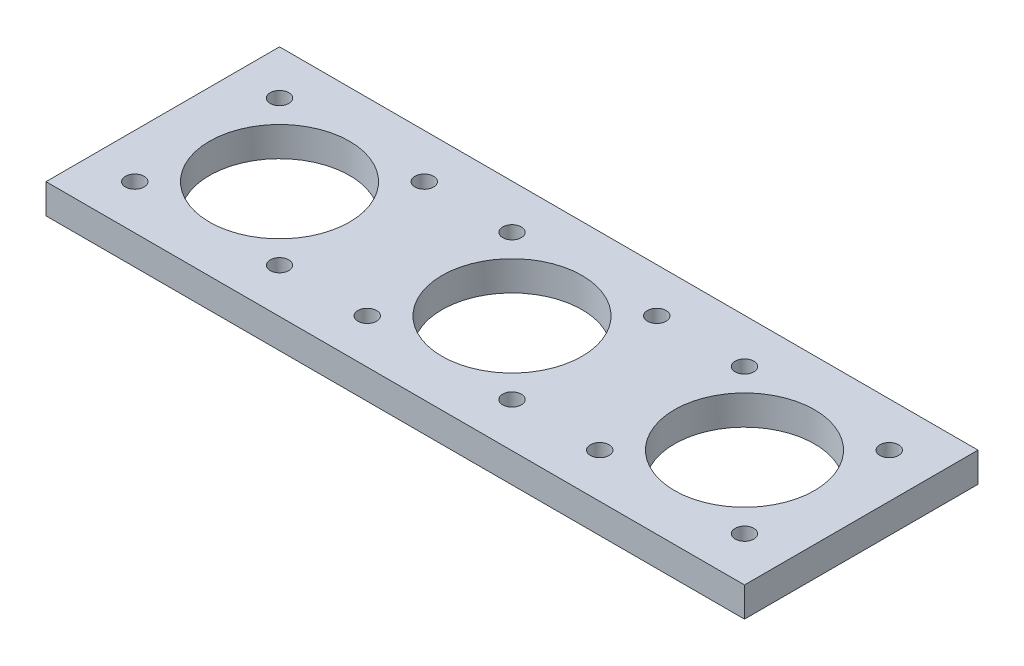
from build123d import *

# Parameters (mm, degrees)
SKETCH1_W               = 50
SKETCH1_H               = 50
BOSS_EXTRUDE1_DEPTH     = 6.35
SKETCH2_R               = 15
CUT_EXTRUDE1_DEPTH      = 1
CUT_EXTRUDE1_DEPTH_BACK = 7.35
SKETCH3_R               = 2
CUT_EXTRUDE2_DEPTH      = 7.35
MIRROR2_COPY_1_SKETCH_R = 2
MIRROR2_COPY_1_DEPTH    = 7.35
LPATTERN2_COUNT         = 3
LPATTERN2_PITCH         = 49.784


with BuildPart() as part:
    # Sketch1 → Boss-Extrude1 (new body)
    with BuildSketch(Plane(origin=(0, 0, 0), x_dir=(1, 0, 0), z_dir=(0, 1, 0))):
        Rectangle(SKETCH1_W, SKETCH1_H)
    extrude(amount=BOSS_EXTRUDE1_DEPTH)

    # Sketch2 → Cut-Extrude1 (cut, two sides)
    with BuildSketch(Plane(origin=(0, 6.35, 0), x_dir=(1, 0, 0), z_dir=(0, 1, 0))) as cut_extrude1_sk:
        Circle(SKETCH2_R)
    extrude(amount=CUT_EXTRUDE1_DEPTH, mode=Mode.SUBTRACT)
    extrude(cut_extrude1_sk.sketch, amount=-CUT_EXTRUDE1_DEPTH_BACK, mode=Mode.SUBTRACT)

    # Sketch3 → Cut-Extrude2 (cut, through all)
    with BuildSketch(Plane(origin=(0, 6.35, 0), x_dir=(1, 0, 0), z_dir=(0, 1, 0))):
        with Locations((-15.5, 15.5)):
            Circle(SKETCH3_R)
    cut_extrude2 = extrude(amount=-CUT_EXTRUDE2_DEPTH, mode=Mode.SUBTRACT)

    # Mirror1: Cut-Extrude2 across plane
    add(cut_extrude2.mirror(Plane(origin=(0, 0, 0), x_dir=(0, 0, 1), z_dir=(1, 0, 0))), mode=Mode.SUBTRACT)

    # Mirror2: Cut-Extrude2 across plane
    add(cut_extrude2.mirror(Plane.XY), mode=Mode.SUBTRACT)

    # Mirror2 copy 1 sketch → Mirror2 copy 1 (cut, through all)
    with BuildSketch(Plane(origin=(0, 6.35, 0), x_dir=(-1, 0, 0), z_dir=(0, 1, 0))):
        with Locations((-15.5, 15.5)):
            Circle(MIRROR2_COPY_1_SKETCH_R)
    extrude(amount=-MIRROR2_COPY_1_DEPTH, mode=Mode.SUBTRACT)


with BuildPart() as lpattern2_1:
    # LPattern2: pattern copy
    add(part.part.moved(Location(Vector(1, 0, 0) * (1 * LPATTERN2_PITCH))))


with BuildPart() as lpattern2_2:
    # LPattern2: pattern copy
    add(part.part.moved(Location(Vector(1, 0, 0) * (2 * LPATTERN2_PITCH))))


with BuildPart() as part_1:
    add(part.part)

    # Combine1: union LPattern2_1, LPattern2_2
    add(lpattern2_1.part)
    add(lpattern2_2.part)


solid = part_1.part
